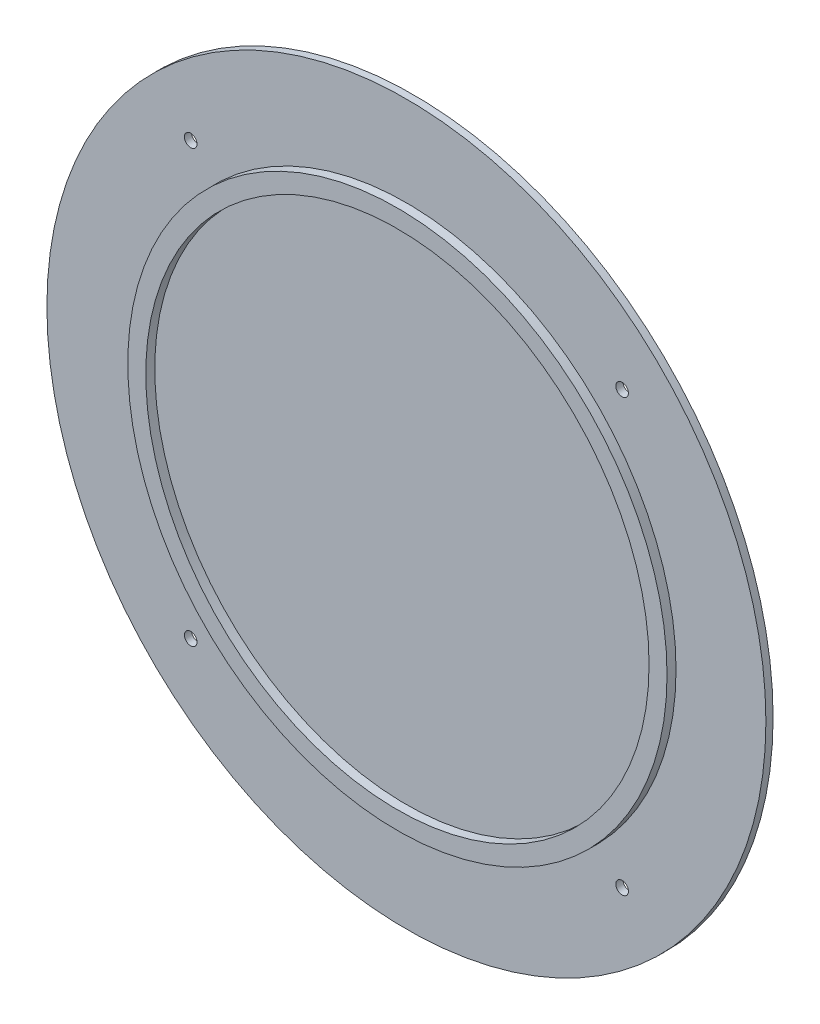
from build123d import *

# Parameters (mm, degrees)
CROQUIS1_R              = 20
SALIENTE_EXTRUIR1_DEPTH = 0.4
CROQUIS3_R              = 0.35
CORTAR_EXTRUIR1_DEPTH   = 10
CROQUIS2_R              = 15
CROQUIS2_R_2            = 14
SALIENTE_EXTRUIR2_DEPTH = 0.5


with BuildPart() as part:
    # Croquis1 → Saliente-Extruir1 (new body)
    with BuildSketch(Plane.XY):
        Circle(CROQUIS1_R)
    extrude(amount=SALIENTE_EXTRUIR1_DEPTH)

    # Croquis3 → Cortar-Extruir1 (cut)
    with BuildSketch(Plane.XY.offset(0.4)):
        with Locations((12, 12)):
            Circle(CROQUIS3_R)
        with Locations((-12, 12)):
            Circle(CROQUIS3_R)
        with Locations((12, -12)):
            Circle(CROQUIS3_R)
        with Locations((-12, -12)):
            Circle(CROQUIS3_R)
    extrude(amount=-CORTAR_EXTRUIR1_DEPTH, mode=Mode.SUBTRACT)

    # Croquis2 → Saliente-Extruir2 (add)
    with BuildSketch(Plane.XY.offset(0.4)):
        Circle(CROQUIS2_R)
        Circle(CROQUIS2_R_2, mode=Mode.SUBTRACT)
    extrude(amount=SALIENTE_EXTRUIR2_DEPTH)


solid = part.part
